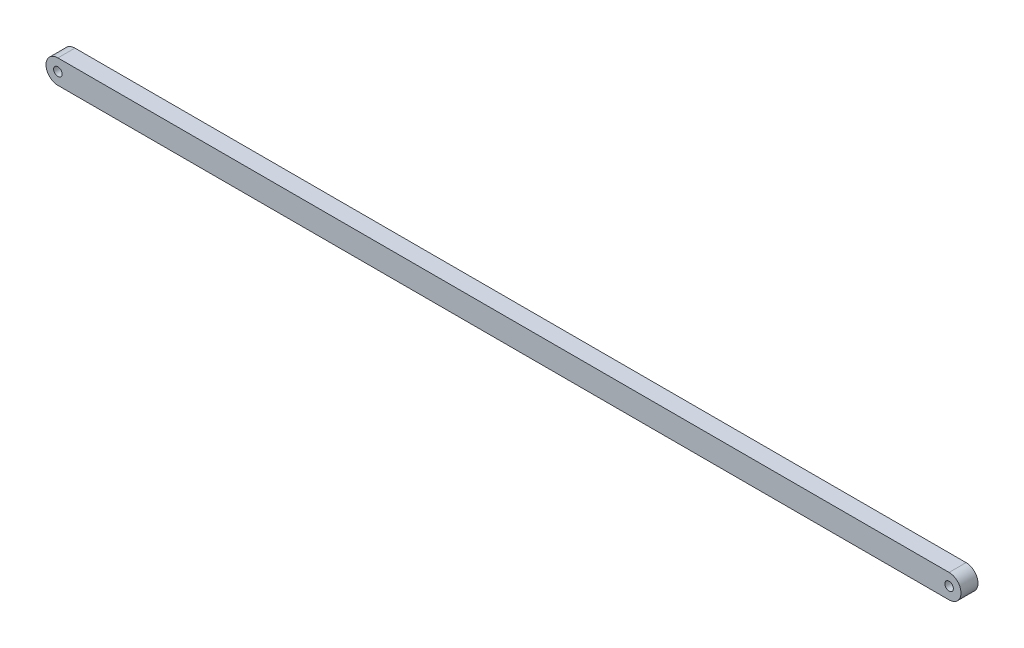
from build123d import *

# Parameters (mm, degrees)
SKETCH1_R           = 2.5
BOSS_EXTRUDE1_DEPTH = 5


with BuildPart() as part:
    # Sketch1 → Boss-Extrude1 (new body, symmetric)
    with BuildSketch(Plane.XY):
        with BuildLine():
            Line((0, 7), (524, 7))
            ThreePointArc((524, 7), (531, 0), (524, -7))
            Line((524, -7), (0, -7))
            ThreePointArc((0, -7), (-7, 0), (0, 7))
        make_face()
        Circle(SKETCH1_R, mode=Mode.SUBTRACT)
        with Locations((524, 0)):
            Circle(SKETCH1_R, mode=Mode.SUBTRACT)
    extrude(amount=BOSS_EXTRUDE1_DEPTH, both=True)


solid = part.part
